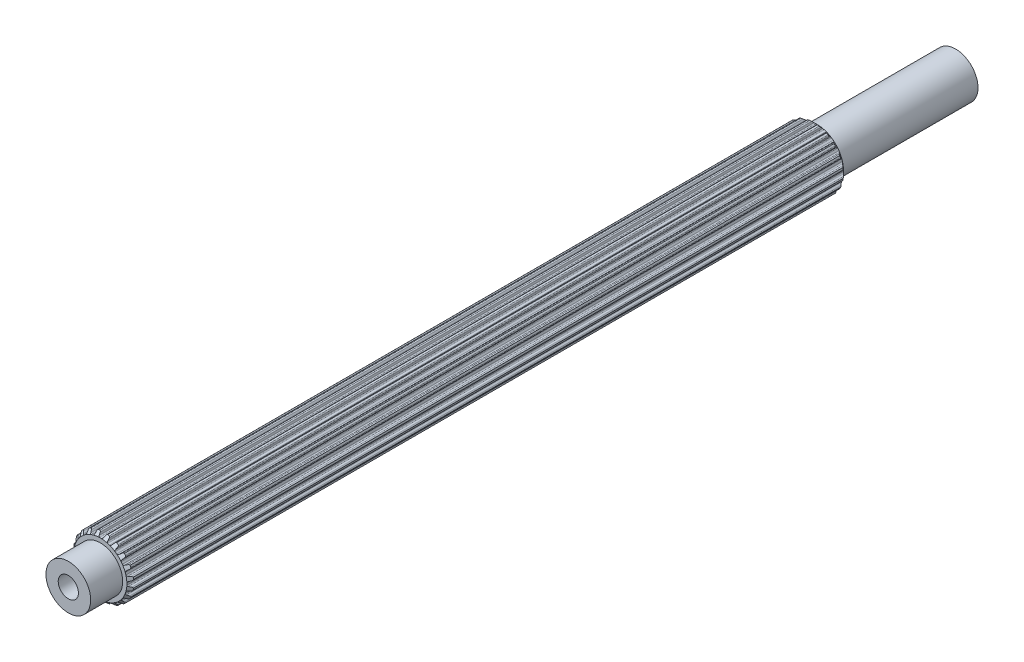
from build123d import *

# Parameters (mm, degrees)
BOSS_EXTRUDE1_DEPTH            = 46.04766
BOSS_EXTRUDE1_DEPTH_BACK       = 34.10966
SKETCH2_R                      = 2.5019
BOSS_EXTRUDE2_DEPTH            = 49.62906
CUT_EXTRUDE1_REACH             = 51.629
SKETCH7_R                      = 1.1303
CUT_EXTRUDE1_DIRECTION_2_REACH = 51.629
SKETCH8_R                      = 1.1303
BOSS_EXTRUDE3_DEPTH            = 40.10406
BOSS_EXTRUDE3_DEPTH_BACK       = 40.10406


with BuildPart() as part:
    # Sketch1 → Boss-Extrude1 (new body, two sides)
    with BuildSketch(Plane.XY) as boss_extrude1_sk:
        with BuildLine():
            Line((-0.106949245, 2.969874934), (0.106949245, 2.969874934))
            ThreePointArc((0.106949245, 2.969874934), (0.196343213, 2.986924176), (0.253739238, 3.057547504))
            Line((0.253739238, 3.057547504), (0.315888147, 3.237526941))
            ThreePointArc((0.315888147, 3.237526941), (0.359032156, 3.298322911), (0.4281449, 3.326269005))
            Line((0.4281449, 3.326269005), (0.620027588, 3.2937547))
            ThreePointArc((0.620027588, 3.2937547), (0.689621142, 3.24802576), (0.718272212, 3.169836791))
            Line((0.718272212, 3.169836791), (0.724389167, 2.979527391))
            ThreePointArc((0.724389167, 2.979527391), (0.750934762, 2.9040661), (0.816027049, 2.857568043))
            Line((0.816027049, 2.857568043), (1.019456602, 2.791469774))
            ThreePointArc((1.019456602, 2.791469774), (1.109743823, 2.780060312), (1.186154496, 2.829490741))
            Line((1.186154496, 2.829490741), (1.300878326, 2.981456288))
            ThreePointArc((1.300878326, 2.981456288), (1.360697704, 3.02594446), (1.435063648, 3.031165762))
            Line((1.435063648, 3.031165762), (1.607507455, 2.940947809))
            ThreePointArc((1.607507455, 2.940947809), (1.659563839, 2.875951412), (1.662650905, 2.792735615))
            Line((1.662650905, 2.792735615), (1.609659636, 2.609850378))
            ThreePointArc((1.609659636, 2.609850378), (1.611587176, 2.529879385), (1.659124931, 2.465542482))
            Line((1.659124931, 2.465542482), (1.832172444, 2.339816104))
            ThreePointArc((1.832172444, 2.339816104), (1.914514976, 2.301064775), (2.002460687, 2.32446371))
            Line((2.002460687, 2.32446371), (2.158529469, 2.433539921))
            ThreePointArc((2.158529469, 2.433539921), (2.229168681, 2.457365482), (2.301508367, 2.439350895))
            Line((2.301508367, 2.439350895), (2.437633293, 2.300260456))
            ThreePointArc((2.437633293, 2.300260456), (2.467056864, 2.222358901), (2.444277744, 2.14226202))
            Line((2.444277744, 2.14226202), (2.337365406, 1.984703026))
            ThreePointArc((2.337365406, 1.984703026), (2.314486209, 1.908050449), (2.339816104, 1.832172444))
            Line((2.339816104, 1.832172444), (2.465542482, 1.659124931))
            ThreePointArc((2.465542482, 1.659124931), (2.531880064, 1.596824985), (2.622752074, 1.591901975))
            Line((2.622752074, 1.591901975), (2.804888709, 1.64741171))
            ThreePointArc((2.804888709, 1.64741171), (2.879433095, 1.648242449), (2.942665411, 1.608755366))
            Line((2.942665411, 1.608755366), (3.0291466, 1.434407582))
            ThreePointArc((3.0291466, 1.434407582), (3.033057175, 1.351226417), (2.986641646, 1.282088892))
            Line((2.986641646, 1.282088892), (2.836273564, 1.165279113))
            ThreePointArc((2.836273564, 1.165279113), (2.790827206, 1.099448241), (2.791469774, 1.019456602))
            Line((2.791469774, 1.019456602), (2.857568043, 0.816027049))
            ThreePointArc((2.857568043, 0.816027049), (2.901407091, 0.736276839), (2.986310214, 0.703513784))
            Line((2.986310214, 0.703513784), (3.1766859, 0.700023363))
            ThreePointArc((3.1766859, 0.700023363), (3.247838536, 0.677777961), (3.295773863, 0.620683653))
            Line((3.295773863, 0.620683653), (3.324145932, 0.4281449))
            ThreePointArc((3.324145932, 0.4281449), (3.302160717, 0.347826477), (3.236652255, 0.29641597))
            Line((3.236652255, 0.29641597), (3.057547504, 0.231789562))
            ThreePointArc((3.057547504, 0.231789562), (2.993982591, 0.183224379), (2.969874934, 0.106949245))
            Line((2.969874934, 0.106949245), (2.969874934, -0.106949245))
            ThreePointArc((2.969874934, -0.106949245), (2.986924176, -0.196343213), (3.057547504, -0.253739238))
            Line((3.057547504, -0.253739238), (3.237526941, -0.315888147))
            ThreePointArc((3.237526941, -0.315888147), (3.298322911, -0.359032156), (3.326269005, -0.4281449))
            Line((3.326269005, -0.4281449), (3.2937547, -0.620027588))
            ThreePointArc((3.2937547, -0.620027588), (3.24802576, -0.689621142), (3.169836791, -0.718272212))
            Line((3.169836791, -0.718272212), (2.979527391, -0.724389167))
            ThreePointArc((2.979527391, -0.724389167), (2.9040661, -0.750934762), (2.857568043, -0.816027049))
            Line((2.857568043, -0.816027049), (2.791469774, -1.019456602))
            ThreePointArc((2.791469774, -1.019456602), (2.780060312, -1.109743823), (2.829490741, -1.186154496))
            Line((2.829490741, -1.186154496), (2.981456288, -1.300878326))
            ThreePointArc((2.981456288, -1.300878326), (3.02594446, -1.360697704), (3.031165762, -1.435063648))
            Line((3.031165762, -1.435063648), (2.940947809, -1.607507455))
            ThreePointArc((2.940947809, -1.607507455), (2.875951412, -1.659563839), (2.792735615, -1.662650905))
            Line((2.792735615, -1.662650905), (2.609850378, -1.609659636))
            ThreePointArc((2.609850378, -1.609659636), (2.529879385, -1.611587176), (2.465542482, -1.659124931))
            Line((2.465542482, -1.659124931), (2.339816104, -1.832172444))
            ThreePointArc((2.339816104, -1.832172444), (2.301064775, -1.914514976), (2.32446371, -2.002460687))
            Line((2.32446371, -2.002460687), (2.433539921, -2.158529469))
            ThreePointArc((2.433539921, -2.158529469), (2.457365482, -2.229168681), (2.439350895, -2.301508367))
            Line((2.439350895, -2.301508367), (2.300260456, -2.437633293))
            ThreePointArc((2.300260456, -2.437633293), (2.222358901, -2.467056864), (2.14226202, -2.444277744))
            Line((2.14226202, -2.444277744), (1.984703026, -2.337365406))
            ThreePointArc((1.984703026, -2.337365406), (1.908050449, -2.314486209), (1.832172444, -2.339816104))
            Line((1.832172444, -2.339816104), (1.659124931, -2.465542482))
            ThreePointArc((1.659124931, -2.465542482), (1.596824985, -2.531880064), (1.591901975, -2.622752074))
            Line((1.591901975, -2.622752074), (1.64741171, -2.804888709))
            ThreePointArc((1.64741171, -2.804888709), (1.648242449, -2.879433095), (1.608755366, -2.942665411))
            Line((1.608755366, -2.942665411), (1.434407582, -3.0291466))
            ThreePointArc((1.434407582, -3.0291466), (1.351226417, -3.033057175), (1.282088892, -2.986641646))
            Line((1.282088892, -2.986641646), (1.165279113, -2.836273564))
            ThreePointArc((1.165279113, -2.836273564), (1.099448241, -2.790827206), (1.019456602, -2.791469774))
            Line((1.019456602, -2.791469774), (0.816027049, -2.857568043))
            ThreePointArc((0.816027049, -2.857568043), (0.736276839, -2.901407091), (0.703513784, -2.986310214))
            Line((0.703513784, -2.986310214), (0.700023363, -3.1766859))
            ThreePointArc((0.700023363, -3.1766859), (0.677777961, -3.247838536), (0.620683653, -3.295773863))
            Line((0.620683653, -3.295773863), (0.4281449, -3.324145932))
            ThreePointArc((0.4281449, -3.324145932), (0.347826477, -3.302160717), (0.29641597, -3.236652255))
            Line((0.29641597, -3.236652255), (0.231789562, -3.057547504))
            ThreePointArc((0.231789562, -3.057547504), (0.183224379, -2.993982591), (0.106949245, -2.969874934))
            Line((0.106949245, -2.969874934), (-0.106949245, -2.969874934))
            ThreePointArc((-0.106949245, -2.969874934), (-0.196343213, -2.986924176), (-0.253739238, -3.057547504))
            Line((-0.253739238, -3.057547504), (-0.315888147, -3.237526941))
            ThreePointArc((-0.315888147, -3.237526941), (-0.359032156, -3.298322911), (-0.4281449, -3.326269005))
            Line((-0.4281449, -3.326269005), (-0.620027588, -3.2937547))
            ThreePointArc((-0.620027588, -3.2937547), (-0.689621142, -3.24802576), (-0.718272212, -3.169836791))
            Line((-0.718272212, -3.169836791), (-0.724389167, -2.979527391))
            ThreePointArc((-0.724389167, -2.979527391), (-0.750934762, -2.9040661), (-0.816027049, -2.857568043))
            Line((-0.816027049, -2.857568043), (-1.019456602, -2.791469774))
            ThreePointArc((-1.019456602, -2.791469774), (-1.109743823, -2.780060312), (-1.186154496, -2.829490741))
            Line((-1.186154496, -2.829490741), (-1.300878326, -2.981456288))
            ThreePointArc((-1.300878326, -2.981456288), (-1.360697704, -3.02594446), (-1.435063648, -3.031165762))
            Line((-1.435063648, -3.031165762), (-1.607507455, -2.940947809))
            ThreePointArc((-1.607507455, -2.940947809), (-1.659563839, -2.875951412), (-1.662650905, -2.792735615))
            Line((-1.662650905, -2.792735615), (-1.609659636, -2.609850378))
            ThreePointArc((-1.609659636, -2.609850378), (-1.611587176, -2.529879385), (-1.659124931, -2.465542482))
            Line((-1.659124931, -2.465542482), (-1.832172444, -2.339816104))
            ThreePointArc((-1.832172444, -2.339816104), (-1.914514976, -2.301064775), (-2.002460687, -2.32446371))
            Line((-2.002460687, -2.32446371), (-2.158529469, -2.433539921))
            ThreePointArc((-2.158529469, -2.433539921), (-2.229168681, -2.457365482), (-2.301508367, -2.439350895))
            Line((-2.301508367, -2.439350895), (-2.437633293, -2.300260456))
            ThreePointArc((-2.437633293, -2.300260456), (-2.467056864, -2.222358901), (-2.444277744, -2.14226202))
            Line((-2.444277744, -2.14226202), (-2.337365406, -1.984703026))
            ThreePointArc((-2.337365406, -1.984703026), (-2.314486209, -1.908050449), (-2.339816104, -1.832172444))
            Line((-2.339816104, -1.832172444), (-2.465542482, -1.659124931))
            ThreePointArc((-2.465542482, -1.659124931), (-2.531880064, -1.596824985), (-2.622752074, -1.591901975))
            Line((-2.622752074, -1.591901975), (-2.804888709, -1.64741171))
            ThreePointArc((-2.804888709, -1.64741171), (-2.879433095, -1.648242449), (-2.942665411, -1.608755366))
            Line((-2.942665411, -1.608755366), (-3.0291466, -1.434407582))
            ThreePointArc((-3.0291466, -1.434407582), (-3.033057175, -1.351226417), (-2.986641646, -1.282088892))
            Line((-2.986641646, -1.282088892), (-2.836273564, -1.165279113))
            ThreePointArc((-2.836273564, -1.165279113), (-2.790827206, -1.099448241), (-2.791469774, -1.019456602))
            Line((-2.791469774, -1.019456602), (-2.857568043, -0.816027049))
            ThreePointArc((-2.857568043, -0.816027049), (-2.901407091, -0.736276839), (-2.986310214, -0.703513784))
            Line((-2.986310214, -0.703513784), (-3.1766859, -0.700023363))
            ThreePointArc((-3.1766859, -0.700023363), (-3.247838536, -0.677777961), (-3.295773863, -0.620683653))
            Line((-3.295773863, -0.620683653), (-3.324145932, -0.4281449))
            ThreePointArc((-3.324145932, -0.4281449), (-3.302160717, -0.347826477), (-3.236652255, -0.29641597))
            Line((-3.236652255, -0.29641597), (-3.057547504, -0.231789562))
            ThreePointArc((-3.057547504, -0.231789562), (-2.993982591, -0.183224379), (-2.969874934, -0.106949245))
            Line((-2.969874934, -0.106949245), (-2.969874934, 0.106949245))
            ThreePointArc((-2.969874934, 0.106949245), (-2.986924176, 0.196343213), (-3.057547504, 0.253739238))
            Line((-3.057547504, 0.253739238), (-3.237526941, 0.315888147))
            ThreePointArc((-3.237526941, 0.315888147), (-3.298322911, 0.359032156), (-3.326269005, 0.4281449))
            Line((-3.326269005, 0.4281449), (-3.2937547, 0.620027588))
            ThreePointArc((-3.2937547, 0.620027588), (-3.24802576, 0.689621142), (-3.169836791, 0.718272212))
            Line((-3.169836791, 0.718272212), (-2.979527391, 0.724389167))
            ThreePointArc((-2.979527391, 0.724389167), (-2.9040661, 0.750934762), (-2.857568043, 0.816027049))
            Line((-2.857568043, 0.816027049), (-2.791469774, 1.019456602))
            ThreePointArc((-2.791469774, 1.019456602), (-2.780060312, 1.109743823), (-2.829490741, 1.186154496))
            Line((-2.829490741, 1.186154496), (-2.981456288, 1.300878326))
            ThreePointArc((-2.981456288, 1.300878326), (-3.02594446, 1.360697704), (-3.031165762, 1.435063648))
            Line((-3.031165762, 1.435063648), (-2.940947809, 1.607507455))
            ThreePointArc((-2.940947809, 1.607507455), (-2.875951412, 1.659563839), (-2.792735615, 1.662650905))
            Line((-2.792735615, 1.662650905), (-2.609850378, 1.609659636))
            ThreePointArc((-2.609850378, 1.609659636), (-2.529879385, 1.611587176), (-2.465542482, 1.659124931))
            Line((-2.465542482, 1.659124931), (-2.339816104, 1.832172444))
            ThreePointArc((-2.339816104, 1.832172444), (-2.301064775, 1.914514976), (-2.32446371, 2.002460687))
            Line((-2.32446371, 2.002460687), (-2.433539921, 2.158529469))
            ThreePointArc((-2.433539921, 2.158529469), (-2.457365482, 2.229168681), (-2.439350895, 2.301508367))
            Line((-2.439350895, 2.301508367), (-2.300260456, 2.437633293))
            ThreePointArc((-2.300260456, 2.437633293), (-2.222358901, 2.467056864), (-2.14226202, 2.444277744))
            Line((-2.14226202, 2.444277744), (-1.984703026, 2.337365406))
            ThreePointArc((-1.984703026, 2.337365406), (-1.908050449, 2.314486209), (-1.832172444, 2.339816104))
            Line((-1.832172444, 2.339816104), (-1.659124931, 2.465542482))
            ThreePointArc((-1.659124931, 2.465542482), (-1.596824985, 2.531880064), (-1.591901975, 2.622752074))
            Line((-1.591901975, 2.622752074), (-1.64741171, 2.804888709))
            ThreePointArc((-1.64741171, 2.804888709), (-1.648242449, 2.879433095), (-1.608755366, 2.942665411))
            Line((-1.608755366, 2.942665411), (-1.434407582, 3.0291466))
            ThreePointArc((-1.434407582, 3.0291466), (-1.351226417, 3.033057175), (-1.282088892, 2.986641646))
            Line((-1.282088892, 2.986641646), (-1.165279113, 2.836273564))
            ThreePointArc((-1.165279113, 2.836273564), (-1.099448241, 2.790827206), (-1.019456602, 2.791469774))
            Line((-1.019456602, 2.791469774), (-0.816027049, 2.857568043))
            ThreePointArc((-0.816027049, 2.857568043), (-0.736276839, 2.901407091), (-0.703513784, 2.986310214))
            Line((-0.703513784, 2.986310214), (-0.700023363, 3.1766859))
            ThreePointArc((-0.700023363, 3.1766859), (-0.677777961, 3.247838536), (-0.620683653, 3.295773863))
            Line((-0.620683653, 3.295773863), (-0.4281449, 3.324145932))
            ThreePointArc((-0.4281449, 3.324145932), (-0.347826477, 3.302160717), (-0.29641597, 3.236652255))
            Line((-0.29641597, 3.236652255), (-0.231789562, 3.057547504))
            ThreePointArc((-0.231789562, 3.057547504), (-0.183224379, 2.993982591), (-0.106949245, 2.969874934))
        make_face()
    extrude(amount=BOSS_EXTRUDE1_DEPTH)
    extrude(boss_extrude1_sk.sketch, amount=-BOSS_EXTRUDE1_DEPTH_BACK)

    # Sketch2 → Boss-Extrude2 (add, symmetric)
    with BuildSketch(Plane.XY):
        Circle(SKETCH2_R)
    extrude(amount=BOSS_EXTRUDE2_DEPTH, both=True)

    # Sketch3 → Cut-Revolve1 (revolve, cut)
    with BuildSketch(Plane(origin=(0, 0, 0), x_dir=(0, 0, -1), z_dir=(1, 0, 0))):
        Polygon((-44.916435505, 4.101099429), (-46.04766, 2.969874934), (-46.04766, 4.101099429), align=None)
        Polygon((34.10966, 30.823529155), (34.10966, 2.969874934), (20.182832889, 16.896702045), align=None)
    revolve(axis=Axis((0, 0, 14.360793934), (0, 0, -1)), mode=Mode.SUBTRACT)

    # Cut-Extrude1: up to this face of the body (flat: up to its plane)
    cut_extrude1_end = Plane(part.part.faces().sort_by_distance((0, 0, -49.62906))[0])
    # Sketch7 → Cut-Extrude1 (cut, up to the picked face)
    with BuildSketch(Plane.XY, mode=Mode.PRIVATE) as cut_extrude1_sk1:
        Circle(SKETCH7_R)
    cut_extrude1_tool1 = split(extrude(cut_extrude1_sk1.sketch, amount=-CUT_EXTRUDE1_REACH, mode=Mode.PRIVATE), bisect_by=cut_extrude1_end, keep=Keep.BOTH, mode=Mode.PRIVATE)
    add(cut_extrude1_tool1.solids().sort_by_distance((0, 0, 0))[0], mode=Mode.SUBTRACT)

    # Cut-Extrude1 direction 2: up to this face of the body (flat: up to its plane)
    cut_extrude1_direction_2_end = Plane(part.part.faces().sort_by_distance((0, 0, 49.62906))[0])
    # Sketch7 → Cut-Extrude1 direction 2 (cut, up to the picked face)
    with BuildSketch(Plane.XY, mode=Mode.PRIVATE) as cut_extrude1_direction_2_sk1:
        Circle(SKETCH7_R)
    cut_extrude1_direction_2_tool1 = split(extrude(cut_extrude1_direction_2_sk1.sketch, amount=CUT_EXTRUDE1_DIRECTION_2_REACH, mode=Mode.PRIVATE), bisect_by=cut_extrude1_direction_2_end, keep=Keep.BOTH, mode=Mode.PRIVATE)
    add(cut_extrude1_direction_2_tool1.solids().sort_by_distance((0, 0, 0))[0], mode=Mode.SUBTRACT)

    # Sketch8 → Boss-Extrude3 (add, two sides)
    with BuildSketch(Plane.XY) as boss_extrude3_sk:
        Circle(SKETCH8_R)
    extrude(amount=BOSS_EXTRUDE3_DEPTH)
    extrude(boss_extrude3_sk.sketch, amount=-BOSS_EXTRUDE3_DEPTH_BACK)


solid = part.part
